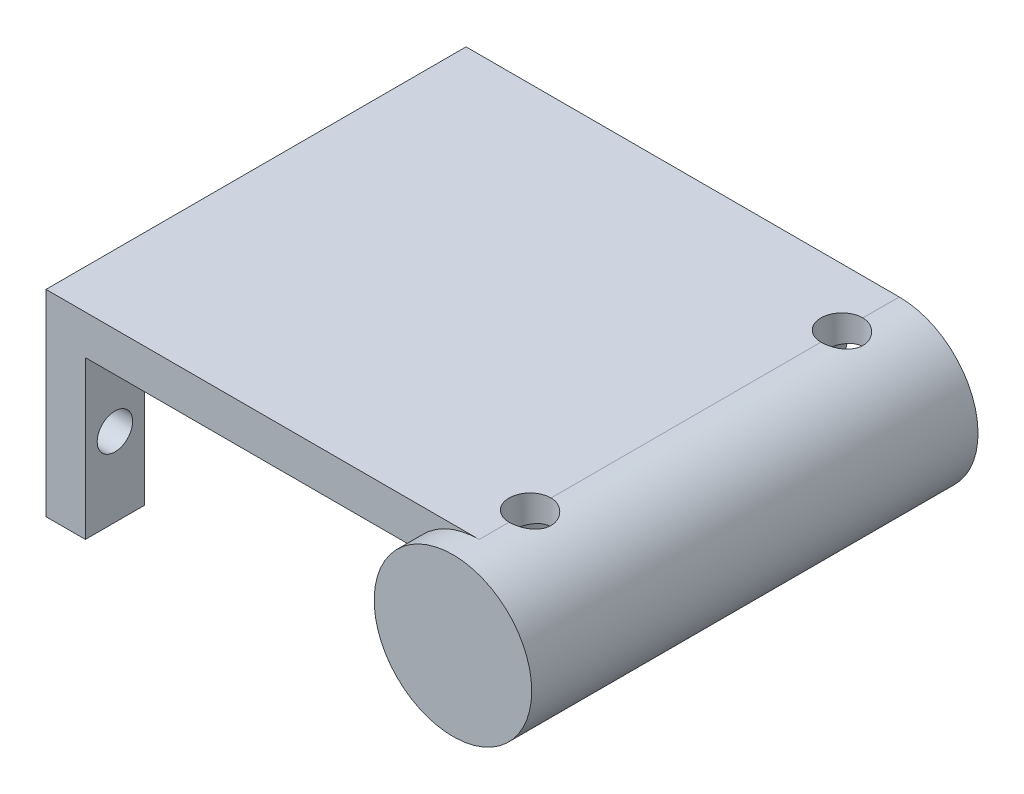
from build123d import *

# Parameters (mm, degrees)
SKETCH_1_R          = 4.1
EXTRUDE_1_DEPTH     = 32
SKETCH_3_R          = 1.35
SKETCH_3_W          = 23
SKETCH_3_H          = 12
CUT_EXTRUDE_1_DEPTH = 5
SKETCH_4_R          = 1.6
CUT_EXTRUDE_2_DEPTH = 10
SKETCH_5_R          = 6
EXTRUDE_2_DEPTH     = 2


with BuildPart() as part:
    # 草图1 → 凸台-拉伸1 (new body)
    with BuildSketch(Plane.XY):
        with BuildLine():
            Line((-32.405771928, 8.673637409), (-5.405771928, 8.673637409))
            Line((-5.405771928, 8.673637409), (0.594228072, 8.673637409))
            ThreePointArc((0.594228072, 8.673637409), (3.594228072, -2.522515014), (-4.601924351, 5.673637409))
            Line((-4.601924351, 5.673637409), (-29.405771928, 5.673637409))
            Line((-29.405771928, 5.673637409), (-29.405771928, -6.326362591))
            Line((-29.405771928, -6.326362591), (-32.405771928, -6.326362591))
            Line((-32.405771928, -6.326362591), (-32.405771928, 5.673637409))
            Line((-32.405771928, 5.673637409), (-32.405771928, 8.673637409))
        make_face()
        with Locations((0.594228072, 2.673637409)):
            Circle(SKETCH_1_R, mode=Mode.SUBTRACT)
    extrude(amount=EXTRUDE_1_DEPTH)

    # 草图3 → 切除-拉伸1 (cut)
    with BuildSketch(Plane.ZY.offset(32.405771928)):
        with Locations((29.75, -0.326362591)):
            Circle(SKETCH_3_R)
        with Locations((2.25, -0.326362591)):
            Circle(SKETCH_3_R)
        with Locations((16, -0.326362591)):
            Rectangle(SKETCH_3_W, SKETCH_3_H)
    extrude(amount=-CUT_EXTRUDE_1_DEPTH, mode=Mode.SUBTRACT)

    # 草图4 → 切除-拉伸2 (cut, symmetric)
    with BuildSketch(Plane(origin=(0, 0, 0), x_dir=(1, 0, 0), z_dir=(0, 1, 0))):
        with Locations((0.594228072, -4.365303353)):
            Circle(SKETCH_4_R)
        with Locations((0.594228072, -28.123934877)):
            Circle(SKETCH_4_R)
    extrude(amount=CUT_EXTRUDE_2_DEPTH, both=True, mode=Mode.SUBTRACT)

    # 草图5 → 凸台-拉伸2 (add)
    with BuildSketch(Plane.XY.offset(32)):
        with Locations((0.594228072, 2.673637409)):
            Circle(SKETCH_5_R)
    extrude(amount=EXTRUDE_2_DEPTH)


solid = part.part
